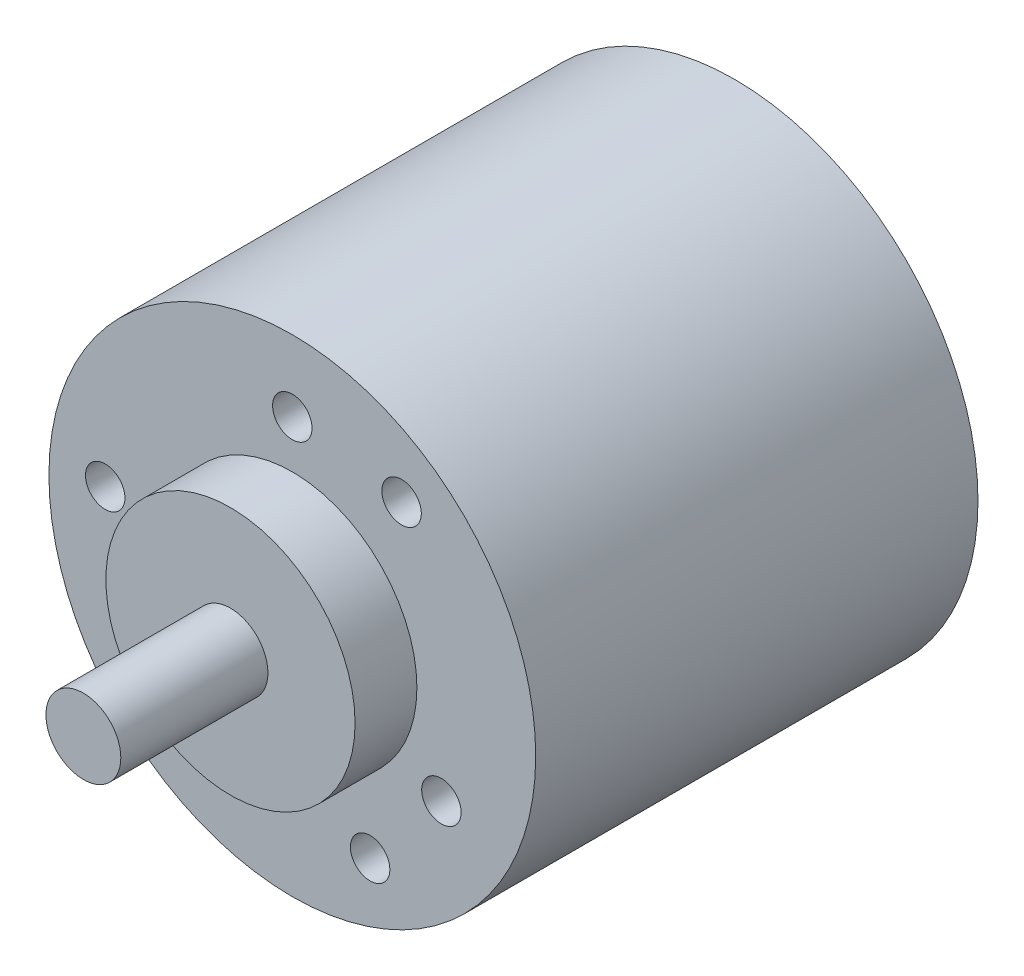
from build123d import *

# Parameters (mm, degrees)
SKETCH1_R           = 19.5
BOSS_EXTRUDE1_DEPTH = 35.433
SKETCH2_R           = 9.9822
BOSS_EXTRUDE2_DEPTH = 4.953
SKETCH4_R           = 3
BOSS_EXTRUDE3_DEPTH = 11.7856
SKETCH5_R           = 1.58
CUT_EXTRUDE1_DEPTH  = 5.08


with BuildPart() as part:
    # Sketch1 → Boss-Extrude1 (new body)
    with BuildSketch(Plane.XY):
        Circle(SKETCH1_R)
    extrude(amount=-BOSS_EXTRUDE1_DEPTH)

    # Sketch2 → Boss-Extrude2 (add)
    with BuildSketch(Plane.XY):
        Circle(SKETCH2_R)
    extrude(amount=BOSS_EXTRUDE2_DEPTH)

    # Sketch4 → Boss-Extrude3 (add)
    with BuildSketch(Plane.XY.offset(4.953)):
        Circle(SKETCH4_R)
    extrude(amount=BOSS_EXTRUDE3_DEPTH)

    # Sketch5 → Cut-Extrude1 (cut)
    with BuildSketch(Plane.XY):
        with Locations((-11.944395574, -6.8961)):
            Circle(SKETCH5_R)
        with Locations((11.944395574, -6.8961)):
            Circle(SKETCH5_R)
        with Locations((0, 13.7922)):
            Circle(SKETCH5_R)
        with Locations((8.755768371, 12.253167763)):
            Circle(SKETCH5_R)
        with Locations((6.233670374, -13.709301721)):
            Circle(SKETCH5_R)
        with Locations((-14.989438745, 1.456133958)):
            Circle(SKETCH5_R)
    extrude(amount=-CUT_EXTRUDE1_DEPTH, mode=Mode.SUBTRACT)


solid = part.part
